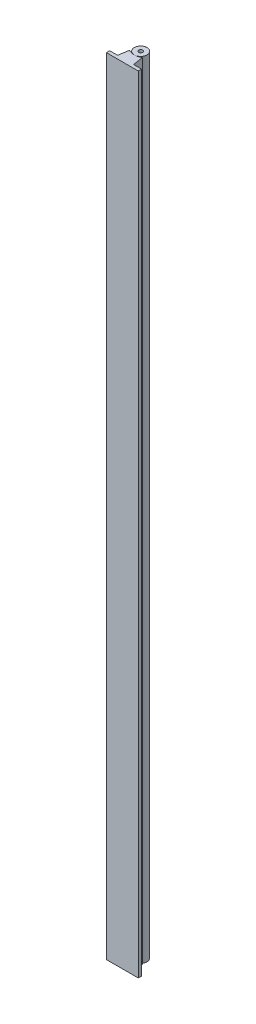
from build123d import *

# Parameters (mm, degrees)
CROQUIS2_R                = 8
SALIENTE_EXTRUIR1_DEPTH   = 985
SALIENTE_EXTRUIR1_2_DEPTH = 985
CROQUIS3_R                = 2.5
CORTAR_EXTRUIR1_DEPTH     = 15
CROQUIS4_R                = 2.5
CORTAR_EXTRUIR2_DEPTH     = 15


with BuildPart() as part:
    # Croquis2 → Saliente-Extruir1 (new body)
    with BuildSketch(Plane(origin=(0, 0, 0), x_dir=(1, 0, 0), z_dir=(0, 1, 0))):
        with Locations((-7.276441578, 16.233656664)):
            Circle(CROQUIS2_R)
    extrude(amount=SALIENTE_EXTRUIR1_DEPTH)

    # Croquis3 → Cortar-Extruir1 (cut)
    with BuildSketch(Plane.XZ):
        with Locations((-7.276441578, -16.233656664)):
            Circle(CROQUIS3_R)
    extrude(amount=-CORTAR_EXTRUIR1_DEPTH, mode=Mode.SUBTRACT)

    # Croquis4 → Cortar-Extruir2 (cut)
    with BuildSketch(Plane(origin=(0, 985, 0), x_dir=(1, 0, 0), z_dir=(0, 1, 0))):
        with Locations((-7.276441578, 16.233656664)):
            Circle(CROQUIS4_R)
    extrude(amount=-CORTAR_EXTRUIR2_DEPTH, mode=Mode.SUBTRACT)


with BuildPart() as body_2:
    # Croquis2 → Saliente-Extruir1 2 (new body)
    with BuildSketch(Plane(origin=(0, 0, 0), x_dir=(1, 0, 0), z_dir=(0, 1, 0))):
        with BuildLine():
            Line((-27.276441578, -6.722749797), (10.823558422, -6.722749797))
            Line((10.823558422, -6.722749797), (12.723558422, -6.722749797))
            Line((12.723558422, -6.722749797), (12.723558422, -2.622749797))
            Line((12.723558422, -2.622749797), (2.723558422, -2.622749797))
            Line((2.723558422, -2.622749797), (0.723558422, 10.377250203))
            ThreePointArc((0.723558422, 10.377250203), (-7.276441578, 8.233656664), (-15.276441578, 10.377250203))
            Line((-15.276441578, 10.377250203), (-17.276441578, -2.622749797))
            Line((-17.276441578, -2.622749797), (-27.276441578, -2.622749797))
            Line((-27.276441578, -2.622749797), (-27.276441578, -6.722749797))
        make_face()
    extrude(amount=SALIENTE_EXTRUIR1_2_DEPTH)


solid = Compound([part.part, body_2.part])
